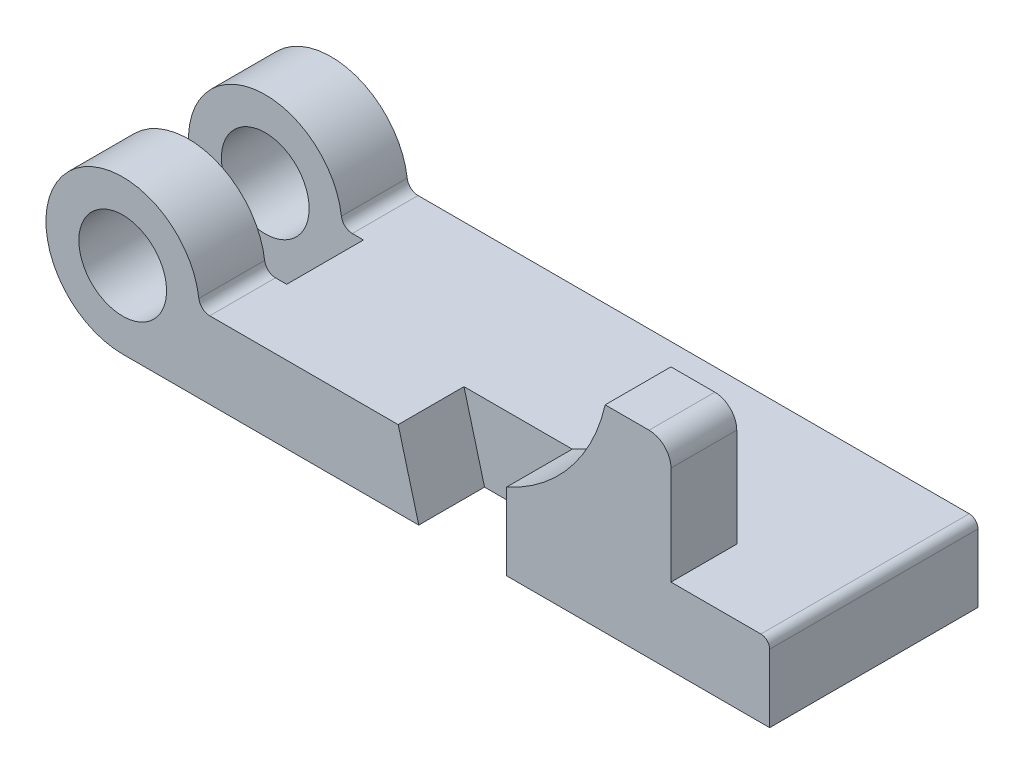
from build123d import *

# Parameters (mm, degrees)
BOSS_EXTRUDE1_DEPTH = 11.1125
BOSS_EXTRUDE2_START = 11.1125
SKETCH1_4_R         = 12.7
BOSS_EXTRUDE2_DEPTH = 19.05
BOSS_EXTRUDE4_START = -11.1125
SKETCH1_6_R         = 22.225
SKETCH1_6_R_2       = 12.7
BOSS_EXTRUDE4_DEPTH = 19.05


with BuildPart() as part:
    # Sketch1 → Boss-Extrude1 (new, symmetric)
    with BuildSketch(Plane.XY):
        with BuildLine():
            Line((28.443390267, 0), (41.275, -22.225))
            Line((41.275, -22.225), (187.325, -22.225))
            Line((187.325, -22.225), (187.325, -2.54))
            ThreePointArc((187.325, -2.54), (186.581051224, -0.743948776), (184.785, 0))
            Line((184.785, 0), (28.443390267, 0))
        make_face()
    extrude(amount=BOSS_EXTRUDE1_DEPTH, both=True)

    # Sketch1_4 → Boss-Extrude2 (add)
    with BuildSketch(Plane.XY.offset(BOSS_EXTRUDE2_START)):
        with BuildLine():
            ThreePointArc((25.200781238, 0), (23.100716135, 0.79375), (22.050683583, 2.778125))
            ThreePointArc((22.050683583, 2.778125), (-16.66875, 14.700455722), (0, -22.225))
            Line((0, -22.225), (85.725, -22.225))
            Line((85.725, -22.225), (79.769829198, 0))
            Line((79.769829198, 0), (25.200781238, 0))
        make_face()
        with Locations(Location((0, 0, 0), (0, 0, 180))):
            Circle(SKETCH1_4_R, mode=Mode.SUBTRACT)
        with BuildLine():
            Line((111.125, 0), (111.125, -22.225))
            Line((111.125, -22.225), (187.325, -22.225))
            Line((187.325, -22.225), (187.325, -2.54))
            ThreePointArc((187.325, -2.54), (186.581051224, -0.743948776), (184.785, 0))
            Line((184.785, 0), (158.75, 0))
            Line((158.75, 0), (158.75, 28.575))
            ThreePointArc((158.75, 28.575), (156.890128061, 33.065128061), (152.4, 34.925))
            Line((152.4, 34.925), (139.7, 34.925))
            ThreePointArc((139.7, 34.925), (129.503262126, 14.115512806), (111.125, 0))
        make_face()
    extrude(amount=BOSS_EXTRUDE2_DEPTH)

    # Sketch1_6 → Boss-Extrude4 (add)
    with BuildSketch(Plane.XY.offset(BOSS_EXTRUDE4_START)):
        Circle(SKETCH1_6_R)
        with Locations(Location((0, 0, 0), (0, 0, 180))):
            Circle(SKETCH1_6_R_2, mode=Mode.SUBTRACT)
        with BuildLine():
            ThreePointArc((22.225, 0), (15.715448212, -15.715448212), (0, -22.225))
            Line((0, -22.225), (41.275, -22.225))
            Line((41.275, -22.225), (28.443390267, 0))
            Line((28.443390267, 0), (25.200781238, 0))
            ThreePointArc((25.200781238, 0), (23.100716135, 0.79375), (22.050683583, 2.778125))
            ThreePointArc((22.050683583, 2.778125), (22.181378087, 1.391794231), (22.225, 0))
        make_face()
        Polygon((28.443390267, 0), (41.275, -22.225), (85.725, -22.225), (79.769829198, 0), align=None)
        with BuildLine():
            Line((187.325, -22.225), (187.325, -2.54))
            ThreePointArc((187.325, -2.54), (186.581051224, -0.743948776), (184.785, 0))
            Line((184.785, 0), (158.75, 0))
            Line((158.75, 0), (111.125, 0))
            Line((111.125, 0), (111.125, -22.225))
            Line((111.125, -22.225), (187.325, -22.225))
        make_face()
        Polygon((85.725, -22.225), (79.769829198, 0), (111.125, 0), (111.125, -22.225), align=None)
    extrude(amount=-BOSS_EXTRUDE4_DEPTH)


solid = part.part
